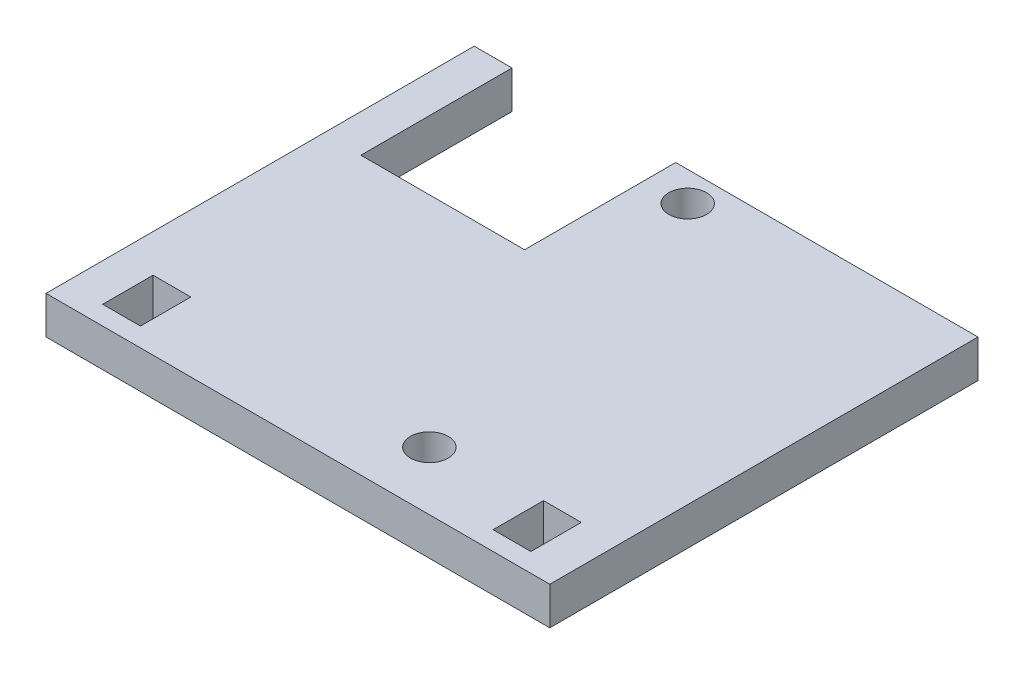
from build123d import *

# Parameters (mm, degrees)
SKETCH1_R           = 1.5
SKETCH1_W           = 3
SKETCH1_H           = 4
BOSS_EXTRUDE1_DEPTH = 3


with BuildPart() as part:
    # Sketch1 → Boss-Extrude1 (new body)
    with BuildSketch(Plane(origin=(0, 0, 0), x_dir=(1, 0, 0), z_dir=(0, 1, 0))):
        Polygon((16, 34), (40, 34), (40, 0), (0, 0), (0, 34), (3, 34), (3, 22), (16, 22), align=None)
        with Locations((19.3, 31.65)):
            Circle(SKETCH1_R, mode=Mode.SUBTRACT)
        with Locations((25.8, 4.64)):
            Circle(SKETCH1_R, mode=Mode.SUBTRACT)
        with Locations((4.5, 3.5)):
            Rectangle(SKETCH1_W, SKETCH1_H, mode=Mode.SUBTRACT)
        with Locations((35.5, 3.5)):
            Rectangle(SKETCH1_W, SKETCH1_H, mode=Mode.SUBTRACT)
    extrude(amount=BOSS_EXTRUDE1_DEPTH)


solid = part.part
